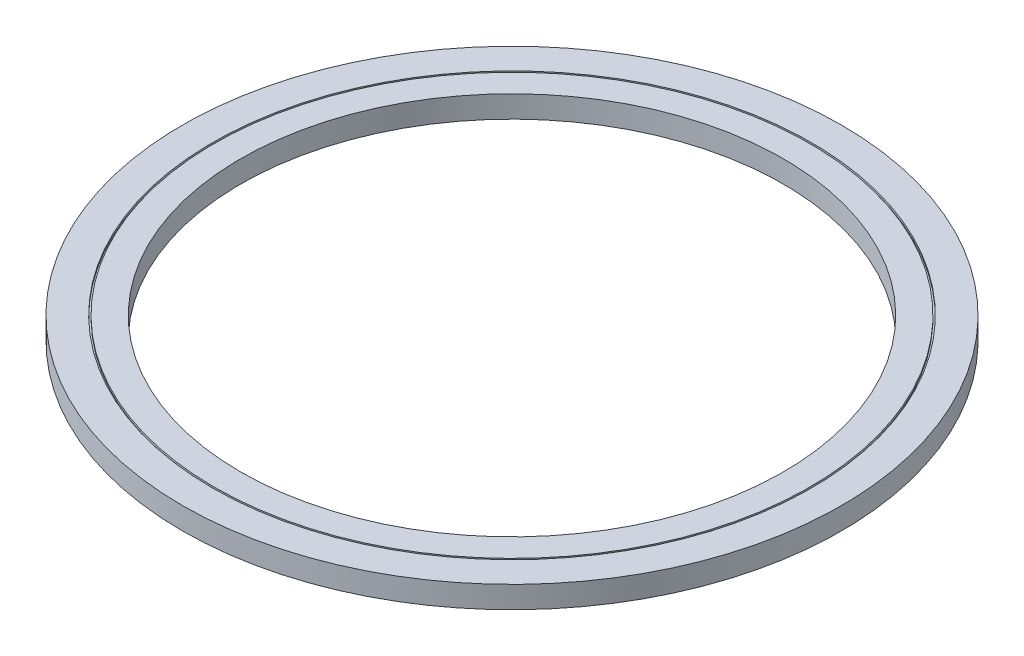
from build123d import *

# Parameters (mm, degrees)
SKETCH1_R           = 150
SKETCH1_R_2         = 123.5
BOSS_EXTRUDE1_DEPTH = 5
SKETCH2_R           = 136.25
SKETCH2_R_2         = 135.5
CUT_EXTRUDE1_DEPTH  = 1


with BuildPart() as part:
    # Sketch1 → Boss-Extrude1 (new body, symmetric)
    with BuildSketch(Plane(origin=(0, 0, 0), x_dir=(1, 0, 0), z_dir=(0, 1, 0))):
        Circle(SKETCH1_R)
        Circle(SKETCH1_R_2, mode=Mode.SUBTRACT)
    extrude(amount=BOSS_EXTRUDE1_DEPTH, both=True)

    # Sketch2 → Cut-Extrude1 (cut)
    with BuildSketch(Plane(origin=(0, 5, 0), x_dir=(1, 0, 0), z_dir=(0, 1, 0))):
        Circle(SKETCH2_R)
        Circle(SKETCH2_R_2, mode=Mode.SUBTRACT)
    cut_extrude1 = extrude(amount=-CUT_EXTRUDE1_DEPTH, mode=Mode.SUBTRACT)

    # Mirror1: Cut-Extrude1 across plane
    add(cut_extrude1.mirror(Plane.ZX), mode=Mode.SUBTRACT)


solid = part.part
